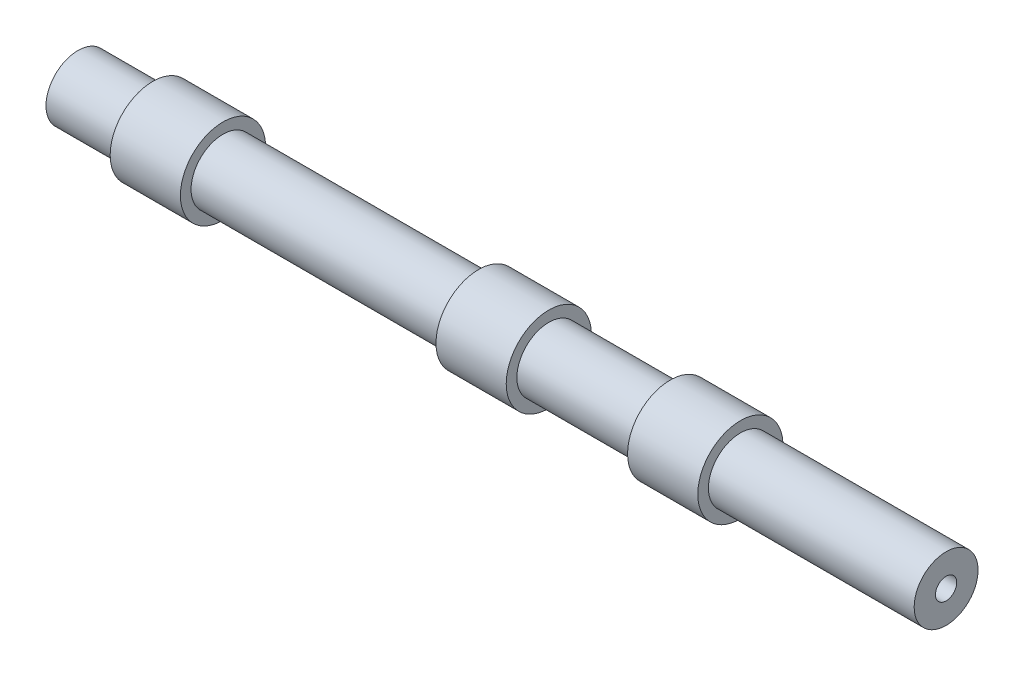
from build123d import *


with BuildPart() as part:
    # Sketch1 → Revolve-Thin1 (revolve)
    with BuildSketch(Plane.XY):
        Polygon((-102.279792746, 15), (-67.150259067, 15), (-67.150259067, 20), (-34.180259067, 20), (-34.180259067, 15), (85.819740933, 15), (85.819740933, 20), (118.789740933, 20), (118.789740933, 15), (175.759740933, 15), (175.759740933, 20), (208.729740933, 20), (208.729740933, 15), (218.211606218, 15), (305.314834779, 15), (305.314834779, 5), (218.211606218, 5), (198.729740933, 5), (198.729740933, 10), (185.759740933, 10), (185.759740933, 5), (108.789740933, 5), (108.789740933, 10), (95.819740933, 10), (95.819740933, 5), (-44.180259067, 5), (-44.180259067, 10), (-57.150259067, 10), (-57.150259067, 5), (-102.279792746, 5), align=None)
    revolve(axis=Axis((-102.279792746, 0, 0), (1, 0, 0)))


solid = part.part
